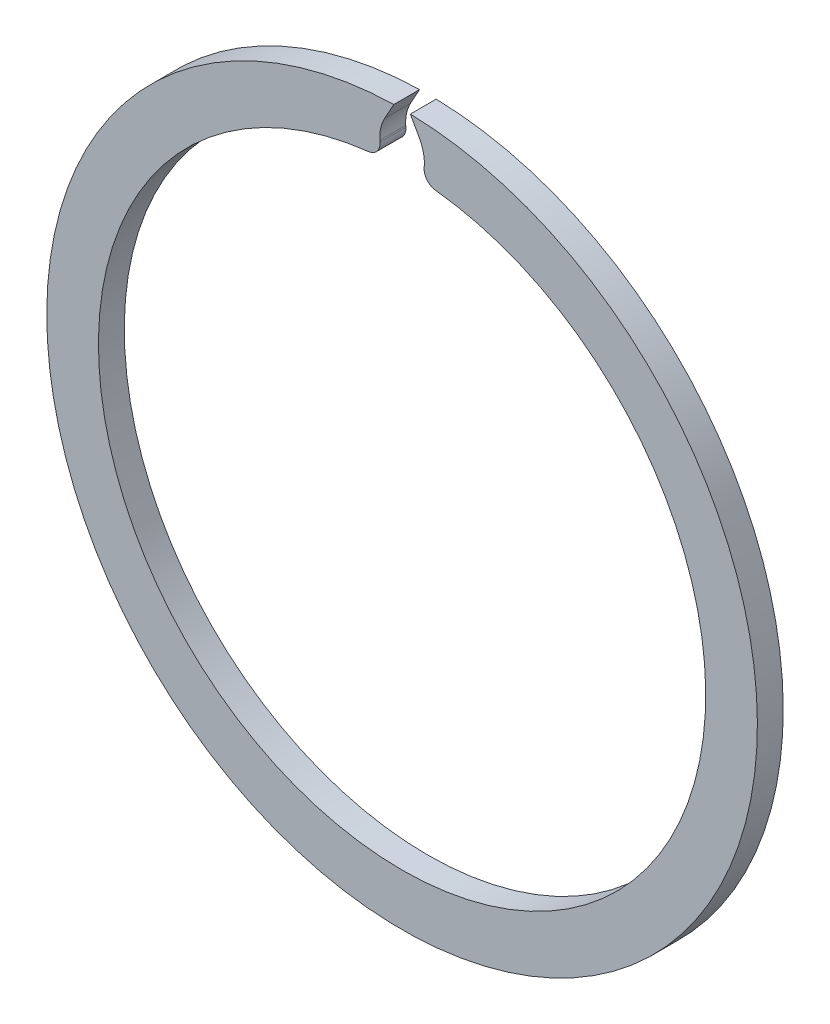
from build123d import *

# Parameters (mm, degrees)
ESTRUSIONE_ESTRUSIONE1_DEPTH = 2


with BuildPart() as part:
    # Schizzo1 → Estrusione-Estrusione1 (new body)
    with BuildSketch(Plane.XY):
        with BuildLine():
            Line((-1.707609412, 24.419952295), (-1.716801654, 24.55140748))
            ThreePointArc((-1.716801654, 24.55140748), (-1.652997524, 25.409995743), (-1.347968624, 26.215105762))
            Line((-1.347968624, 26.215105762), (-0.639867053, 27.492554813))
            ThreePointArc((-0.639867053, 27.492554813), (0, -27.5), (0.639867053, 27.492554813))
            Line((0.639867053, 27.492554813), (1.347968624, 26.215105762))
            ThreePointArc((1.347968624, 26.215105762), (1.652997524, 25.409995743), (1.716801654, 24.55140748))
            Line((1.716801654, 24.55140748), (1.707609412, 24.419952295))
            ThreePointArc((1.707609412, 24.419952295), (1.937229379, 23.709678932), (2.594758219, 23.356310278))
            ThreePointArc((2.594758219, 23.356310278), (0, -23.5), (-2.594758219, 23.356310278))
            ThreePointArc((-2.594758219, 23.356310278), (-1.937229379, 23.709678932), (-1.707609412, 24.419952295))
        make_face()
    extrude(amount=ESTRUSIONE_ESTRUSIONE1_DEPTH)


solid = part.part
